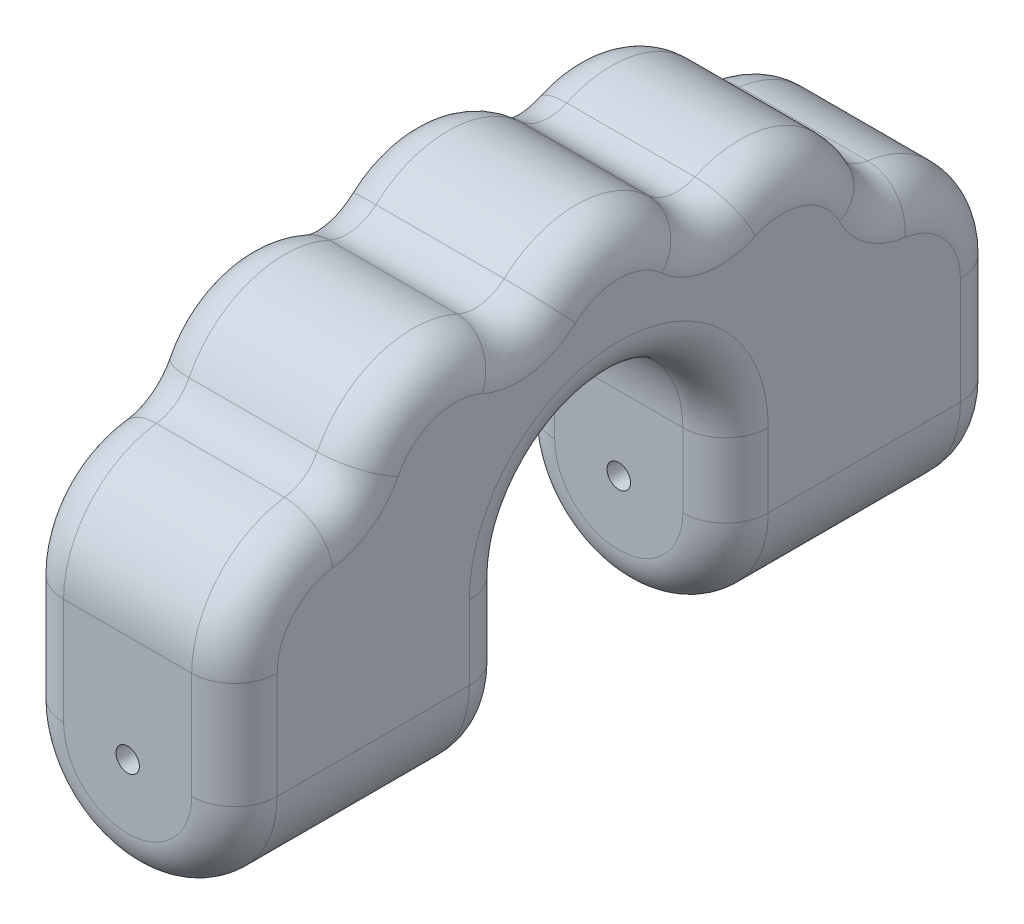
from build123d import *

# Parameters (mm, degrees)
EXTRUDE_1_DEPTH     = 18
CUT_EXTRUDE_1_DEPTH = 6
SKETCH_3_R          = 0.274367176
CUT_EXTRUDE_2_DEPTH = 19
FILLET_1_R          = 1
FILLET_2_R          = 1


with BuildPart() as part:
    # Эскиз1 → Бобышка-Вытянуть1 (new body)
    with BuildSketch(Plane.XY):
        with BuildLine():
            Line((-2.5, 0), (-2.5, 7.5))
            Line((-2.5, 7.5), (2.5, 7.5))
            Line((2.5, 7.5), (2.5, 0))
            ThreePointArc((2.5, 0), (0, -2.5), (-2.5, 0))
        make_face()
    extrude(amount=EXTRUDE_1_DEPTH)

    # Эскиз2 → Вырез-Вытянуть1 (cut, through all)
    with BuildSketch(Plane(origin=(2.5, 0, 0), x_dir=(0, 0, -1), z_dir=(1, 0, 0))):
        with BuildLine():
            Line((-18, 2.5), (-18, 8.150544397))
            Line((-18, 8.150544397), (0, 8.150544397))
            Line((0, 8.150544397), (0, 2.5))
            ThreePointArc((0, 2.5), (-0.820177727, 4.351539125), (-2.742557705, 4.988205329))
            ThreePointArc((-2.742557705, 4.988205329), (-4.430502259, 6.790648336), (-6.843102403, 6.264038273))
            ThreePointArc((-6.843102403, 6.264038273), (-9, 7.5), (-11.156897597, 6.264038273))
            ThreePointArc((-11.156897597, 6.264038273), (-13.569497741, 6.790648336), (-15.257442295, 4.988205329))
            ThreePointArc((-15.257442295, 4.988205329), (-17.179822273, 4.351539125), (-18, 2.5))
        make_face()
        with BuildLine():
            Line((-11.5, 1.730499203), (-11.5, -3.555972199))
            Line((-11.5, -3.555972199), (-6.5, -3.555972199))
            Line((-6.5, -3.555972199), (-6.5, 1.730499203))
            ThreePointArc((-6.5, 1.730499203), (-9, 4.230499203), (-11.5, 1.730499203))
        make_face()
    extrude(amount=-CUT_EXTRUDE_1_DEPTH, mode=Mode.SUBTRACT)

    # Эскиз3 → Вырез-Вытянуть2 (cut, through all)
    with BuildSketch(Plane(origin=(0, 0, 0), x_dir=(-1, 0, 0), z_dir=(0, 0, -1))):
        Circle(SKETCH_3_R)
    extrude(amount=-CUT_EXTRUDE_2_DEPTH, mode=Mode.SUBTRACT)

    # Скругление1
    fillet_1_edges = [part.edges().sort_by_distance(p)[0] for p in [
        (0, 6.264038273, 6.843102403),
        (0, 6.264038273, 11.156897597),
        (0, 4.988205329, 15.257442295),
        (0, 4.988205329, 2.742557705),
    ]]
    fillet(fillet_1_edges, radius=FILLET_1_R)

    # Скругление2
    fillet_2_edges = [part.edges().sort_by_distance(p)[0] for p in [
        (-2.5, 1.25, 0),
        (-2.5, 1.25, 18),
        (2.5, 4.148426978, 17.379544758),
        (-2.5, 4.148426978, 17.379544758),
        (0, -2.5, 18),
        (-2.5, 0.865249601, 6.5),
        (2.5, 0.865249601, 11.5),
        (2.5, 0.865249601, 6.5),
        (2.5, 4.230499203, 9),
        (0, -2.5, 6.5),
        (-2.5, 0.865249601, 11.5),
        (0, -2.5, 11.5),
        (-2.5, 4.230499203, 9),
        (2.5, 1.25, 0),
        (0, -2.5, 0),
        (2.5, 1.25, 18),
        (2.5, 4.148426978, 0.620455242),
        (-2.5, 4.148426978, 0.620455242),
        (2.5, 6.762465879, 4.345340523),
        (-2.5, 6.762465879, 4.345340523),
        (2.5, 7.5, 9),
        (-2.5, 7.5, 9),
        (2.5, 6.762465879, 13.654659477),
        (-2.5, 6.762465879, 13.654659477),
        (2.5, 5.155501136, 2.623431365),
        (-2.5, 5.155501136, 2.623431365),
        (2.5, 6.594385937, 6.791611414),
        (-2.5, 6.594385937, 6.791611414),
        (2.5, 6.594385937, 11.208388586),
        (-2.5, 6.594385937, 11.208388586),
        (2.5, 5.155501136, 15.376568635),
        (-2.5, 5.155501136, 15.376568635),
    ]]
    fillet(fillet_2_edges, radius=FILLET_2_R)


solid = part.part
